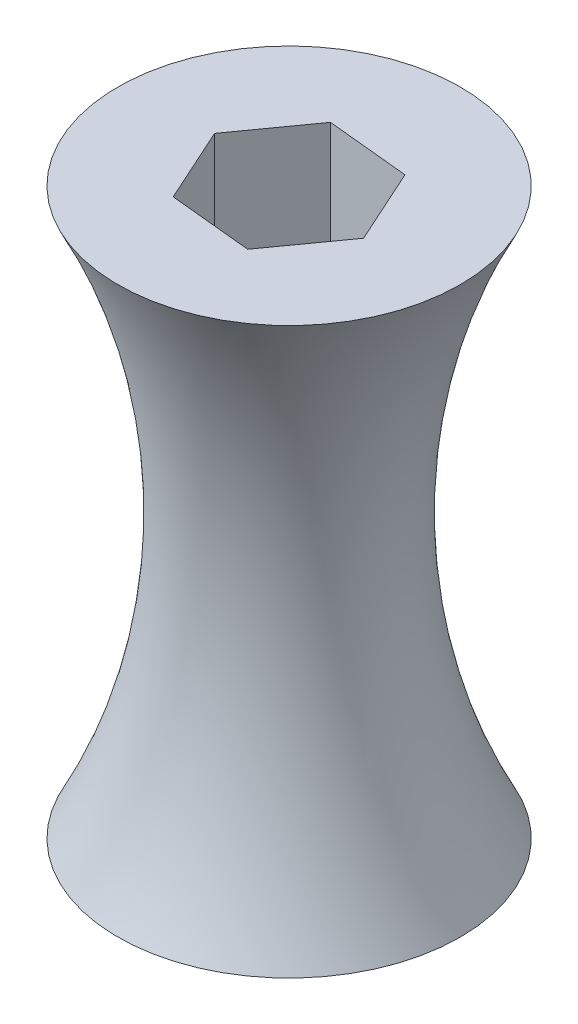
from build123d import *

# Parameters (mm, degrees)
SKETCH1_R           = 19.05
BOSS_EXTRUDE1_DEPTH = 104.775
CUT_EXTRUDE1_DEPTH  = 104.775


with BuildPart() as part:
    # Sketch1 → Boss-Extrude1 (new body)
    with BuildSketch(Plane(origin=(0, 0, 0), x_dir=(1, 0, 0), z_dir=(0, 1, 0))):
        Circle(SKETCH1_R)
    extrude(amount=BOSS_EXTRUDE1_DEPTH)

    # Sketch2 → Cut-Extrude1 (cut)
    with BuildSketch(Plane.XZ):
        Polygon((-15.323636661, -1.510781079), (-6.353443536, -14.026049167), (8.970193125, -12.515268087), (15.323636661, 1.510781079), (6.353443536, 14.026049167), (-8.970193125, 12.515268087), align=None)
    extrude(amount=-CUT_EXTRUDE1_DEPTH, mode=Mode.SUBTRACT)

    # Sketch4 → Revolve3 (revolve)
    with BuildSketch(Plane.XY):
        with BuildLine():
            Line((-19.05, 52.3875), (-19.05, 104.775))
            Line((-19.05, 104.775), (-31.75, 104.775))
            ThreePointArc((-31.75, 104.775), (-22.270325917, 79.339958869), (-19.05, 52.3875))
        make_face()
        with BuildLine():
            Line((-19.05, 0), (-19.05, 52.3875))
            ThreePointArc((-19.05, 52.3875), (-22.270325917, 25.435041131), (-31.75, 0))
            Line((-31.75, 0), (-19.05, 0))
        make_face()
    revolve(axis=Axis((0, 0, 0), (0, 1, 0)))


solid = part.part
